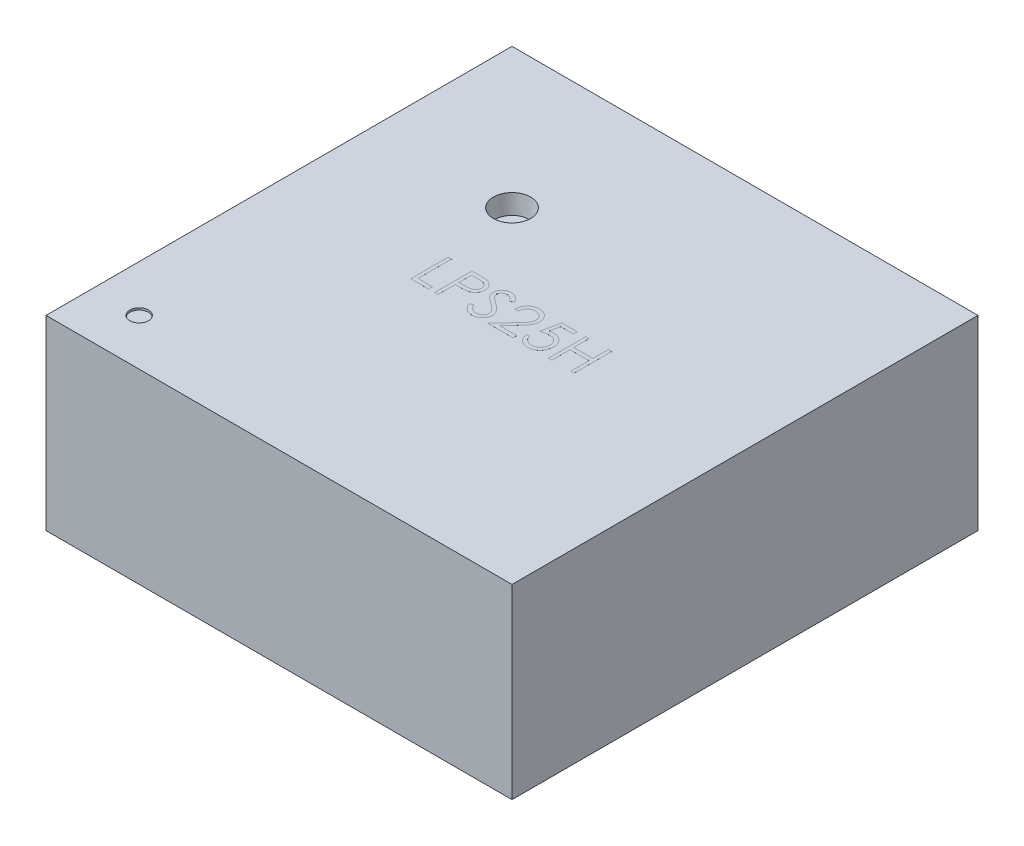
from build123d import *

# Parameters (mm, degrees)
SKETCH1_W           = 2.5
SKETCH1_H           = 2.5
BOSS_EXTRUDE1_DEPTH = 1
SKETCH2_R           = 0.1
CUT_EXTRUDE1_DEPTH  = 0.1
CUT_EXTRUDE1_TAPER  = 5
SKETCH3_R           = 0.05
CUT_EXTRUDE2_DEPTH  = 0.01
CUT_EXTRUDE2_TAPER  = 5
SKETCH4_R           = 0.075
CUT_EXTRUDE3_DEPTH  = 0.01
SKETCH5_W           = 0.45
SKETCH5_H           = 0.3
SKETCH5_W_2         = 0.3
SKETCH5_H_2         = 0.45
BOSS_EXTRUDE2_DEPTH = 0.025
BOSS_EXTRUDE3_DEPTH = 0.0001


with BuildPart() as part:
    # Sketch1 → Boss-Extrude1 (new body)
    with BuildSketch(Plane(origin=(0, 0, 0), x_dir=(1, 0, 0), z_dir=(0, 1, 0))):
        Rectangle(SKETCH1_W, SKETCH1_H)
    extrude(amount=BOSS_EXTRUDE1_DEPTH)

    # Sketch2 → Cut-Extrude1 (cut)
    with BuildSketch(Plane(origin=(0, 1, 0), x_dir=(1, 0, 0), z_dir=(0, 1, 0))):
        with Locations((-0.5, 0.5)):
            Circle(SKETCH2_R)
    extrude(amount=-CUT_EXTRUDE1_DEPTH, taper=CUT_EXTRUDE1_TAPER, mode=Mode.SUBTRACT)

    # Sketch3 → Cut-Extrude2 (cut)
    with BuildSketch(Plane(origin=(0, 1, 0), x_dir=(1, 0, 0), z_dir=(0, 1, 0))):
        with Locations((-1, -1)):
            Circle(SKETCH3_R)
    extrude(amount=-CUT_EXTRUDE2_DEPTH, taper=CUT_EXTRUDE2_TAPER, mode=Mode.SUBTRACT)

    # Sketch4 → Cut-Extrude3 (cut)
    with BuildSketch(Plane.XZ):
        with Locations((-0.75, 1.01)):
            Circle(SKETCH4_R)
    extrude(amount=-CUT_EXTRUDE3_DEPTH, mode=Mode.SUBTRACT)

    # Sketch5 → Boss-Extrude2 (add)
    with BuildSketch(Plane.XZ):
        with Locations((-0.925, 0.6)):
            Rectangle(SKETCH5_W, SKETCH5_H)
        with Locations((-0.925, 0)):
            Rectangle(SKETCH5_W, SKETCH5_H)
        with Locations((-0.925, -0.6)):
            Rectangle(SKETCH5_W, SKETCH5_H)
        with Locations((0.925, -0.6)):
            Rectangle(SKETCH5_W, SKETCH5_H)
        with Locations((0.925, 0.6)):
            Rectangle(SKETCH5_W, SKETCH5_H)
        with Locations((0.925, 0)):
            Rectangle(SKETCH5_W, SKETCH5_H)
        with Locations((-0.3, 0.925)):
            Rectangle(SKETCH5_W_2, SKETCH5_H_2)
        with Locations((0.3, 0.925)):
            Rectangle(SKETCH5_W_2, SKETCH5_H_2)
        with Locations((0.3, -0.925)):
            Rectangle(SKETCH5_W_2, SKETCH5_H_2)
        with Locations((-0.3, -0.925)):
            Rectangle(SKETCH5_W_2, SKETCH5_H_2)
    extrude(amount=BOSS_EXTRUDE2_DEPTH)

    # Sketch6 → Boss-Extrude3 (add)
    with BuildSketch(Plane(origin=(0, 1, 0), x_dir=(1, 0, 0), z_dir=(0, 1, 0))):
        Polygon((-0.441672664, 0.098543738), (-0.423723946, 0.098543738), (-0.423723946, -0.080943441), (-0.346800869, -0.080943441), (-0.346800869, -0.101456262), (-0.441672664, -0.101456262), align=None)
        with BuildLine():
            Line((-0.313467536, 0.098543738), (-0.274244779, 0.098543738))
            add(Edge.make_bspline(
                [(-0.274244779, 0.098543738), (-0.271547013, 0.098540773), (-0.266377974, 0.098535091), (-0.258965685, 0.09836282), (-0.2522337, 0.098132723), (-0.246196536, 0.097813758), (-0.240835616, 0.09743681), (-0.236175199, 0.096908122), (-0.232178653, 0.096356105), (-0.229783998, 0.095794882), (-0.228691895, 0.095538931)],
                knots=[0, 0, 0, 0, 8.093e-06, 1.5507e-05, 2.2242e-05, 2.83e-05, 3.3643e-05, 3.836e-05, 4.2371e-05, 4.5735e-05, 4.5735e-05, 4.5735e-05, 4.5735e-05], degree=3))
            add(Edge.make_bspline(
                [(-0.228691895, 0.095538931), (-0.227309407, 0.095160534), (-0.224577009, 0.094412656), (-0.220639806, 0.092914729), (-0.216893872, 0.091138605), (-0.213326354, 0.08911438), (-0.209981093, 0.086755205), (-0.206808176, 0.084156712), (-0.203835606, 0.081258908), (-0.201080097, 0.078094295), (-0.198549538, 0.074715997), (-0.196370699, 0.071073584), (-0.194546286, 0.067228367), (-0.192981527, 0.06318302), (-0.19185533, 0.058903573), (-0.191006936, 0.05441976), (-0.190468443, 0.049732064), (-0.190416868, 0.046528643), (-0.190390613, 0.044897905)],
                knots=[0, 0, 0, 0, 4.298e-06, 8.495e-06, 1.2617e-05, 1.6726e-05, 2.0783e-05, 2.4882e-05, 2.9018e-05, 3.3221e-05, 3.746e-05, 4.1665e-05, 4.593e-05, 5.0215e-05, 5.4657e-05, 5.9183e-05, 6.3899e-05, 6.879e-05, 6.879e-05, 6.879e-05, 6.879e-05], degree=3))
            add(Edge.make_bspline(
                [(-0.190390613, 0.044897905), (-0.190414694, 0.043253461), (-0.190461811, 0.040035994), (-0.191027313, 0.035328978), (-0.191789038, 0.030830784), (-0.192960299, 0.026551387), (-0.194494337, 0.0225162), (-0.196293883, 0.018663558), (-0.19846437, 0.015059005), (-0.200958361, 0.011689456), (-0.203732737, 0.008551747), (-0.206775762, 0.005668615), (-0.210075151, 0.003056939), (-0.213620416, 0.000710862), (-0.217446122, -0.001315211), (-0.221494245, -0.003129914), (-0.225799972, -0.004653975), (-0.228779544, -0.005455692), (-0.230294459, -0.005863313)],
                knots=[0, 0, 0, 0, 4.93e-06, 9.647e-06, 1.4205e-05, 1.8608e-05, 2.2931e-05, 2.7143e-05, 3.1348e-05, 3.5531e-05, 3.9703e-05, 4.3897e-05, 4.8089e-05, 5.2312e-05, 5.6632e-05, 6.1062e-05, 6.5611e-05, 7.0316e-05, 7.0316e-05, 7.0316e-05, 7.0316e-05], degree=3))
            add(Edge.make_bspline(
                [(-0.230294459, -0.005863313), (-0.231547449, -0.006129769), (-0.234293451, -0.006713723), (-0.238815892, -0.007365635), (-0.244081343, -0.007922069), (-0.250082616, -0.008339277), (-0.256814325, -0.008696441), (-0.264280111, -0.008980332), (-0.27249463, -0.009136324), (-0.278224415, -0.009144369), (-0.281215933, -0.009148569)],
                knots=[0, 0, 0, 0, 3.842e-06, 8.42e-06, 1.3699e-05, 1.9724e-05, 2.6465e-05, 3.3922e-05, 4.2137e-05, 5.1111e-05, 5.1111e-05, 5.1111e-05, 5.1111e-05], degree=3))
            Line((-0.281215933, -0.009148569), (-0.295518818, -0.009148569))
            Line((-0.295518818, -0.009148569), (-0.295518818, -0.101456262))
            Line((-0.295518818, -0.101456262), (-0.313467536, -0.101456262))
            Line((-0.313467536, -0.101456262), (-0.313467536, 0.098543738))
        make_face()
        with BuildLine():
            Line((-0.295518818, 0.078030918), (-0.295518818, 0.011364251))
            Line((-0.295518818, 0.011364251), (-0.260502792, 0.010923546))
            add(Edge.make_bspline(
                [(-0.260502792, 0.010923546), (-0.258793082, 0.010922662), (-0.255492522, 0.010920957), (-0.250724738, 0.011148684), (-0.24630135, 0.011411571), (-0.242235946, 0.011796481), (-0.238526693, 0.012340553), (-0.235167405, 0.012889795), (-0.232184132, 0.013684387), (-0.228692749, 0.014754277), (-0.224802272, 0.016578998), (-0.220569841, 0.019227563), (-0.21698295, 0.022603604), (-0.213879047, 0.02639948), (-0.211415854, 0.030622287), (-0.209612655, 0.035140512), (-0.20855316, 0.039907818), (-0.208411092, 0.043169997), (-0.208339331, 0.044817777)],
                knots=[0, 0, 0, 0, 5.128e-06, 9.9e-06, 1.4316e-05, 1.8422e-05, 2.2145e-05, 2.5563e-05, 2.8624e-05, 3.1399e-05, 3.6509e-05, 4.1465e-05, 4.6314e-05, 5.1213e-05, 5.6133e-05, 6.0917e-05, 6.5758e-05, 7.0699e-05, 7.0699e-05, 7.0699e-05, 7.0699e-05], degree=3))
            add(Edge.make_bspline(
                [(-0.208339331, 0.044817777), (-0.208411482, 0.046425692), (-0.20855491, 0.049622028), (-0.209620959, 0.054306529), (-0.211412348, 0.05877714), (-0.213895582, 0.062947031), (-0.216909361, 0.066729248), (-0.220412181, 0.070014798), (-0.224395796, 0.072656039), (-0.228101409, 0.074360798), (-0.231392905, 0.07540167), (-0.234251874, 0.076129947), (-0.237479913, 0.07671141), (-0.241078072, 0.077182239), (-0.245018462, 0.077585294), (-0.249334937, 0.077858778), (-0.254011146, 0.078018862), (-0.257257464, 0.078026802), (-0.258940292, 0.078030918)],
                knots=[0, 0, 0, 0, 4.821e-06, 9.584e-06, 1.433e-05, 1.9216e-05, 2.409e-05, 2.8796e-05, 3.3563e-05, 3.8367e-05, 4.0977e-05, 4.3912e-05, 4.7212e-05, 5.081e-05, 5.4797e-05, 5.9093e-05, 6.3783e-05, 6.8831e-05, 6.8831e-05, 6.8831e-05, 6.8831e-05], degree=3))
            Line((-0.258940292, 0.078030918), (-0.295518818, 0.078030918))
        make_face(mode=Mode.SUBTRACT)
        with BuildLine():
            Line((-0.169877792, -0.062874531), (-0.152970741, -0.052738313))
            add(Edge.make_bspline(
                [(-0.152970741, -0.052738313), (-0.15139827, -0.055370563), (-0.148385477, -0.060413854), (-0.143359685, -0.067228599), (-0.13815209, -0.073020722), (-0.132724128, -0.077756529), (-0.127108931, -0.081485036), (-0.121269843, -0.084125164), (-0.115226539, -0.085771791), (-0.111113749, -0.085971796), (-0.109060485, -0.086071646)],
                knots=[0, 0, 0, 0, 9.194e-06, 1.7616e-05, 2.5359e-05, 3.2516e-05, 3.9172e-05, 4.5502e-05, 5.1673e-05, 5.7824e-05, 5.7824e-05, 5.7824e-05, 5.7824e-05], degree=3))
            add(Edge.make_bspline(
                [(-0.109060485, -0.086071646), (-0.10730695, -0.086022808), (-0.103830563, -0.085925985), (-0.09871272, -0.084995654), (-0.093742332, -0.083566389), (-0.089021838, -0.081519479), (-0.084616374, -0.079042994), (-0.080753135, -0.076051784), (-0.077413357, -0.072702858), (-0.074681407, -0.068966706), (-0.072585405, -0.064948583), (-0.07097443, -0.060824243), (-0.070080426, -0.056528897), (-0.069945754, -0.05363687), (-0.069877792, -0.052177415)],
                knots=[0, 0, 0, 0, 5.256e-06, 1.042e-05, 1.5554e-05, 2.0741e-05, 2.582e-05, 3.0676e-05, 3.5351e-05, 3.9967e-05, 4.4501e-05, 4.8913e-05, 5.3211e-05, 5.759e-05, 5.759e-05, 5.759e-05, 5.759e-05], degree=3))
            add(Edge.make_bspline(
                [(-0.069877792, -0.052177415), (-0.069962039, -0.050512224), (-0.070133299, -0.047127133), (-0.071580812, -0.042132867), (-0.073857912, -0.037190435), (-0.075958635, -0.03413322), (-0.077049267, -0.032546005)],
                knots=[0, 0, 0, 0, 4.987e-06, 1.0139e-05, 1.5481e-05, 2.1248e-05, 2.1248e-05, 2.1248e-05, 2.1248e-05], degree=3))
            add(Edge.make_bspline(
                [(-0.077049267, -0.032546005), (-0.07794473, -0.031400472), (-0.079824644, -0.02899557), (-0.083056502, -0.025415842), (-0.086848852, -0.021723361), (-0.091071912, -0.017777129), (-0.095879517, -0.013760683), (-0.101121089, -0.009482496), (-0.106930453, -0.005105263), (-0.111004709, -0.002169688), (-0.113106959, -0.00065498)],
                knots=[0, 0, 0, 0, 4.361e-06, 9.156e-06, 1.4453e-05, 2.0237e-05, 2.649e-05, 3.3242e-05, 4.0533e-05, 4.8307e-05, 4.8307e-05, 4.8307e-05, 4.8307e-05], degree=3))
            add(Edge.make_bspline(
                [(-0.113106959, -0.00065498), (-0.115211187, 0.000843797), (-0.119234312, 0.003709343), (-0.124860516, 0.00796216), (-0.129891629, 0.011850381), (-0.134305287, 0.01541061), (-0.138099549, 0.01864333), (-0.141304316, 0.021517498), (-0.143837948, 0.024110844), (-0.145246838, 0.025793207), (-0.145879395, 0.026548546)],
                knots=[0, 0, 0, 0, 7.75e-06, 1.4817e-05, 2.1156e-05, 2.6825e-05, 3.1827e-05, 3.6109e-05, 3.9736e-05, 4.2691e-05, 4.2691e-05, 4.2691e-05, 4.2691e-05], degree=3))
            add(Edge.make_bspline(
                [(-0.145879395, 0.026548546), (-0.14676354, 0.027725748), (-0.148502331, 0.030040874), (-0.150797531, 0.033659437), (-0.152748341, 0.037363624), (-0.154277617, 0.041163388), (-0.155565401, 0.045005384), (-0.156431568, 0.048939741), (-0.156973934, 0.052948804), (-0.157029476, 0.055646719), (-0.157057279, 0.056997264)],
                knots=[0, 0, 0, 0, 4.415e-06, 8.684e-06, 1.2841e-05, 1.6955e-05, 2.0959e-05, 2.4983e-05, 2.9023e-05, 3.3073e-05, 3.3073e-05, 3.3073e-05, 3.3073e-05], degree=3))
            add(Edge.make_bspline(
                [(-0.157057279, 0.056997264), (-0.156982696, 0.059113251), (-0.156835124, 0.063299998), (-0.155587094, 0.069416045), (-0.153617214, 0.075255269), (-0.150857506, 0.080759859), (-0.147299943, 0.085786487), (-0.143183031, 0.090392972), (-0.138279517, 0.094265462), (-0.132899367, 0.097649009), (-0.127010432, 0.100297347), (-0.120839523, 0.102295117), (-0.114376833, 0.103427075), (-0.109999511, 0.103589519), (-0.107778433, 0.103671944)],
                knots=[0, 0, 0, 0, 6.343e-06, 1.255e-05, 1.8644e-05, 2.479e-05, 3.0947e-05, 3.7073e-05, 4.3255e-05, 4.9625e-05, 5.6097e-05, 6.2572e-05, 6.904e-05, 7.5703e-05, 7.5703e-05, 7.5703e-05, 7.5703e-05], degree=3))
            add(Edge.make_bspline(
                [(-0.107778433, 0.103671944), (-0.105421628, 0.103590655), (-0.100734693, 0.103428998), (-0.093840452, 0.102023424), (-0.087202697, 0.099697672), (-0.081863082, 0.09705832), (-0.077684067, 0.094422239), (-0.074497054, 0.092021106), (-0.071267485, 0.089256814), (-0.067969311, 0.086122), (-0.064658416, 0.0825879), (-0.061285647, 0.078678718), (-0.057843117, 0.074418343), (-0.055628497, 0.071376943), (-0.054493177, 0.069817777)],
                knots=[0, 0, 0, 0, 7.065e-06, 1.405e-05, 2.1006e-05, 2.8119e-05, 3.1865e-05, 3.5815e-05, 4.0078e-05, 4.4613e-05, 4.9459e-05, 5.46e-05, 6.01e-05, 6.5885e-05, 6.5885e-05, 6.5885e-05, 6.5885e-05], degree=3))
            Line((-0.054493177, 0.069817777), (-0.070719138, 0.057518097))
            add(Edge.make_bspline(
                [(-0.070719138, 0.057518097), (-0.071698906, 0.058780308), (-0.073585709, 0.061211031), (-0.076450251, 0.064615106), (-0.079150174, 0.06772462), (-0.081810197, 0.070425484), (-0.084289833, 0.072865606), (-0.086696521, 0.074954735), (-0.088995627, 0.07671334), (-0.091893736, 0.078590115), (-0.095534749, 0.080450487), (-0.100105294, 0.08202472), (-0.104881652, 0.082970723), (-0.108134774, 0.083095803), (-0.109781638, 0.083159123)],
                knots=[0, 0, 0, 0, 4.793e-06, 9.23e-06, 1.3346e-05, 1.7142e-05, 2.0599e-05, 2.378e-05, 2.6697e-05, 2.9275e-05, 3.4131e-05, 3.892e-05, 4.3737e-05, 4.8675e-05, 4.8675e-05, 4.8675e-05, 4.8675e-05], degree=3))
            add(Edge.make_bspline(
                [(-0.109781638, 0.083159123), (-0.111847725, 0.083089883), (-0.11583198, 0.08295636), (-0.121488565, 0.081498075), (-0.126579646, 0.079201969), (-0.130954078, 0.07598397), (-0.134596191, 0.072171342), (-0.137230789, 0.067783979), (-0.138816513, 0.06293927), (-0.139010014, 0.059559747), (-0.139108562, 0.05783861)],
                knots=[0, 0, 0, 0, 6.186e-06, 1.1928e-05, 1.7396e-05, 2.2845e-05, 2.8117e-05, 3.3113e-05, 3.8079e-05, 4.3234e-05, 4.3234e-05, 4.3234e-05, 4.3234e-05], degree=3))
            add(Edge.make_bspline(
                [(-0.139108562, 0.05783861), (-0.139086097, 0.056767097), (-0.139041132, 0.054622319), (-0.138414, 0.051453666), (-0.137608324, 0.048293018), (-0.136331603, 0.045154585), (-0.134569014, 0.041983479), (-0.132254432, 0.038725094), (-0.129339386, 0.03535071), (-0.127106414, 0.033156003), (-0.125927472, 0.031997264)],
                knots=[0, 0, 0, 0, 3.209e-06, 6.424e-06, 9.66e-06, 1.2985e-05, 1.6554e-05, 2.0522e-05, 2.4954e-05, 2.9912e-05, 2.9912e-05, 2.9912e-05, 2.9912e-05], degree=3))
            add(Edge.make_bspline(
                [(-0.125927472, 0.031997264), (-0.125489679, 0.031606577), (-0.124449584, 0.030678394), (-0.122548102, 0.029158835), (-0.120037085, 0.027284391), (-0.116982102, 0.024965115), (-0.113326825, 0.022274746), (-0.10907085, 0.019247682), (-0.104261619, 0.015785656), (-0.100848939, 0.013365225), (-0.099044459, 0.012085405)],
                knots=[0, 0, 0, 0, 1.76e-06, 4.182e-06, 7.299e-06, 1.1161e-05, 1.5688e-05, 2.0914e-05, 2.6829e-05, 3.3465e-05, 3.3465e-05, 3.3465e-05, 3.3465e-05], degree=3))
            add(Edge.make_bspline(
                [(-0.099044459, 0.012085405), (-0.096873835, 0.010505899), (-0.092670724, 0.007447404), (-0.08669029, 0.002852222), (-0.081267787, -0.001641936), (-0.076384175, -0.006006371), (-0.071991209, -0.010207976), (-0.068137625, -0.014297301), (-0.064784158, -0.018245048), (-0.061173917, -0.023306338), (-0.057484898, -0.0295224), (-0.054316812, -0.037138299), (-0.052319192, -0.044783803), (-0.052057963, -0.049922479), (-0.051929074, -0.052457864)],
                knots=[0, 0, 0, 0, 8.053e-06, 1.5594e-05, 2.2622e-05, 2.9176e-05, 3.524e-05, 4.0852e-05, 4.6028e-05, 5.0764e-05, 5.9491e-05, 6.7645e-05, 7.5448e-05, 8.3047e-05, 8.3047e-05, 8.3047e-05, 8.3047e-05], degree=3))
            add(Edge.make_bspline(
                [(-0.051929074, -0.052457864), (-0.051966625, -0.054250914), (-0.052040997, -0.057802193), (-0.052895907, -0.063016768), (-0.054148459, -0.06808139), (-0.056036301, -0.072933453), (-0.058340481, -0.077661725), (-0.061264267, -0.082142177), (-0.064653278, -0.086473971), (-0.068540921, -0.090541599), (-0.072794973, -0.094275667), (-0.077291184, -0.097597328), (-0.082036914, -0.100366947), (-0.087006418, -0.102626995), (-0.092200837, -0.104394624), (-0.097618425, -0.10567536), (-0.103268111, -0.1064614), (-0.107108138, -0.106542987), (-0.109060485, -0.106584467)],
                knots=[0, 0, 0, 0, 5.374e-06, 1.0644e-05, 1.5813e-05, 2.0999e-05, 2.6231e-05, 3.1566e-05, 3.7016e-05, 4.2712e-05, 4.8418e-05, 5.3979e-05, 5.9456e-05, 6.487e-05, 7.0331e-05, 7.5889e-05, 8.155e-05, 8.7404e-05, 8.7404e-05, 8.7404e-05, 8.7404e-05], degree=3))
            add(Edge.make_bspline(
                [(-0.109060485, -0.106584467), (-0.110571076, -0.106555256), (-0.113573233, -0.106497203), (-0.118013775, -0.105983987), (-0.122364609, -0.105257867), (-0.126571139, -0.104105063), (-0.130687563, -0.102706379), (-0.134695976, -0.100984188), (-0.138598322, -0.098920348), (-0.14241647, -0.096560633), (-0.146140708, -0.093814476), (-0.149736106, -0.09061599), (-0.153320631, -0.08705339), (-0.156788483, -0.083029929), (-0.160209805, -0.07861061), (-0.163517143, -0.073754085), (-0.166778955, -0.068486808), (-0.168825553, -0.064780232), (-0.169877792, -0.062874531)],
                knots=[0, 0, 0, 0, 4.53e-06, 9.003e-06, 1.3396e-05, 1.775e-05, 2.2071e-05, 2.6432e-05, 3.0822e-05, 3.5303e-05, 3.9886e-05, 4.4684e-05, 4.9727e-05, 5.5037e-05, 6.0607e-05, 6.6485e-05, 7.2656e-05, 7.9186e-05, 7.9186e-05, 7.9186e-05, 7.9186e-05], degree=3))
        make_face()
        with BuildLine():
            Line((-0.003211126, 0.037005277), (-0.021159844, 0.037005277))
            add(Edge.make_bspline(
                [(-0.021159844, 0.037005277), (-0.021042863, 0.03938647), (-0.020813117, 0.044063071), (-0.019737215, 0.05088158), (-0.018197737, 0.057398997), (-0.016021082, 0.063562992), (-0.013317866, 0.069428067), (-0.01007615, 0.074970925), (-0.006236502, 0.080170422), (-0.001881831, 0.084978356), (0.002847805, 0.089389074), (0.007951002, 0.093197945), (0.013313575, 0.096416098), (0.018919255, 0.099106454), (0.024831287, 0.101125874), (0.030996022, 0.102624253), (0.037440544, 0.103525759), (0.041831402, 0.103622661), (0.044064515, 0.103671944)],
                knots=[0, 0, 0, 0, 7.148e-06, 1.4038e-05, 2.0675e-05, 2.7213e-05, 3.3612e-05, 4.0023e-05, 4.6442e-05, 5.2966e-05, 5.9459e-05, 6.5813e-05, 7.2031e-05, 7.8196e-05, 8.443e-05, 9.0736e-05, 9.7207e-05, 0.000103903, 0.000103903, 0.000103903, 0.000103903], degree=3))
            add(Edge.make_bspline(
                [(0.044064515, 0.103671944), (0.046257548, 0.103620603), (0.050566779, 0.103519721), (0.056856037, 0.102653377), (0.062843311, 0.101296486), (0.068516898, 0.099392748), (0.07383153, 0.096833637), (0.078827133, 0.093759492), (0.083563179, 0.090204073), (0.087826424, 0.086018141), (0.091741171, 0.081549434), (0.095118443, 0.076778696), (0.098010624, 0.071851309), (0.100421348, 0.066729697), (0.102195985, 0.061365638), (0.103543311, 0.055837227), (0.104304877, 0.050087237), (0.104421759, 0.046195434), (0.104481182, 0.044216815)],
                knots=[0, 0, 0, 0, 6.576e-06, 1.2923e-05, 1.9007e-05, 2.4974e-05, 3.0834e-05, 3.6661e-05, 4.255e-05, 4.8557e-05, 5.455e-05, 6.0353e-05, 6.6063e-05, 7.1673e-05, 7.7299e-05, 8.2983e-05, 8.8723e-05, 9.4659e-05, 9.4659e-05, 9.4659e-05, 9.4659e-05], degree=3))
            add(Edge.make_bspline(
                [(0.104481182, 0.044216815), (0.104384424, 0.041431225), (0.104192606, 0.035908927), (0.102551785, 0.027793792), (0.099989127, 0.019931311), (0.096903564, 0.013603465), (0.093790853, 0.008504408), (0.090985852, 0.004306196), (0.087702149, -0.000214116), (0.083891949, -0.005041392), (0.079634071, -0.010213444), (0.074889947, -0.015727147), (0.069625748, -0.021525534), (0.065930976, -0.025485854), (0.064016438, -0.027537992)],
                knots=[0, 0, 0, 0, 8.35e-06, 1.6553e-05, 2.4737e-05, 3.3105e-05, 3.7599e-05, 4.2655e-05, 4.8248e-05, 5.4355e-05, 6.1101e-05, 6.8345e-05, 7.6174e-05, 8.4594e-05, 8.4594e-05, 8.4594e-05, 8.4594e-05], degree=3))
            Line((0.064016438, -0.027537992), (0.013976374, -0.080943441))
            Line((0.013976374, -0.080943441), (0.107045285, -0.080943441))
            Line((0.107045285, -0.080943441), (0.107045285, -0.101456262))
            Line((0.107045285, -0.101456262), (-0.028852151, -0.101456262))
            Line((-0.028852151, -0.101456262), (0.048711951, -0.018683826))
            add(Edge.make_bspline(
                [(0.048711951, -0.018683826), (0.050600402, -0.016712494), (0.054227729, -0.012925969), (0.059358162, -0.0073978), (0.063966104, -0.002269255), (0.068081384, 0.002449977), (0.071614727, 0.006828923), (0.074750283, 0.010725764), (0.077262603, 0.014311732), (0.079989197, 0.018468339), (0.082629996, 0.023543328), (0.084899273, 0.029745253), (0.086282979, 0.036129668), (0.086448969, 0.04044407), (0.086532464, 0.042614251)],
                knots=[0, 0, 0, 0, 8.19e-06, 1.5731e-05, 2.2625e-05, 2.8874e-05, 3.4511e-05, 3.9505e-05, 4.3873e-05, 4.7641e-05, 5.4414e-05, 6.0979e-05, 6.7407e-05, 7.3912e-05, 7.3912e-05, 7.3912e-05, 7.3912e-05], degree=3))
            add(Edge.make_bspline(
                [(0.086532464, 0.042614251), (0.086496136, 0.043978903), (0.08642454, 0.046668368), (0.085792672, 0.050611555), (0.084837786, 0.054415258), (0.083469485, 0.058091179), (0.081663386, 0.061602359), (0.079464907, 0.064953073), (0.076928332, 0.068192442), (0.073993974, 0.071229773), (0.070770458, 0.074011556), (0.067365073, 0.07647579), (0.063762209, 0.078535168), (0.05997706, 0.080223368), (0.056020176, 0.081547675), (0.051883905, 0.082465308), (0.047579675, 0.08304145), (0.044640618, 0.083119403), (0.043143041, 0.083159123)],
                knots=[0, 0, 0, 0, 4.091e-06, 8.063e-06, 1.195e-05, 1.5842e-05, 1.9802e-05, 2.3769e-05, 2.7849e-05, 3.2128e-05, 3.6417e-05, 4.0608e-05, 4.4718e-05, 4.8843e-05, 5.3024e-05, 5.7213e-05, 6.1536e-05, 6.6028e-05, 6.6028e-05, 6.6028e-05, 6.6028e-05], degree=3))
            add(Edge.make_bspline(
                [(0.043143041, 0.083159123), (0.041578993, 0.083118264), (0.038507462, 0.083038024), (0.033997803, 0.082476729), (0.029695759, 0.081508395), (0.025590507, 0.080184014), (0.021675102, 0.078500668), (0.017968585, 0.076403997), (0.014479278, 0.073902083), (0.011200619, 0.07106548), (0.00817982, 0.067907331), (0.005525713, 0.064386762), (0.003206627, 0.060568052), (0.001183242, 0.056461506), (-0.000459941, 0.052029862), (-0.001715549, 0.04728885), (-0.002709083, 0.042259057), (-0.003040999, 0.038785624), (-0.003211126, 0.037005277)],
                knots=[0, 0, 0, 0, 4.692e-06, 9.214e-06, 1.3607e-05, 1.7902e-05, 2.2137e-05, 2.6371e-05, 3.0651e-05, 3.4997e-05, 3.9361e-05, 4.3736e-05, 4.8196e-05, 5.2747e-05, 5.745e-05, 6.2348e-05, 6.7448e-05, 7.281e-05, 7.281e-05, 7.281e-05, 7.281e-05], degree=3))
        make_face()
        with BuildLine():
            Line((0.250635028, 0.098543738), (0.250635028, 0.078030918))
            Line((0.250635028, 0.078030918), (0.182606182, 0.078030918))
            Line((0.182606182, 0.078030918), (0.171828938, 0.025426751))
            add(Edge.make_bspline(
                [(0.171828938, 0.025426751), (0.173946417, 0.026011338), (0.178048697, 0.027143883), (0.184103546, 0.028401356), (0.189851672, 0.029159381), (0.193581693, 0.029262884), (0.195386631, 0.029312969)],
                knots=[0, 0, 0, 0, 6.589e-06, 1.2765e-05, 1.8539e-05, 2.3953e-05, 2.3953e-05, 2.3953e-05, 2.3953e-05], degree=3))
            add(Edge.make_bspline(
                [(0.195386631, 0.029312969), (0.197619987, 0.02926463), (0.202011324, 0.029169583), (0.208436407, 0.028256906), (0.214569715, 0.026820339), (0.220398422, 0.024813452), (0.225933311, 0.022247182), (0.231123457, 0.019041471), (0.236046766, 0.015296709), (0.240614915, 0.01099128), (0.244759161, 0.006252902), (0.248402932, 0.001158167), (0.251497937, -0.004243414), (0.253987123, -0.010003449), (0.255974799, -0.016058258), (0.25729777, -0.022471548), (0.258178725, -0.029182869), (0.258277147, -0.033771702), (0.258327336, -0.03611171)],
                knots=[0, 0, 0, 0, 6.697e-06, 1.3167e-05, 1.9425e-05, 2.557e-05, 3.1629e-05, 3.7689e-05, 4.3835e-05, 5.0156e-05, 5.6487e-05, 6.2691e-05, 6.8918e-05, 7.5125e-05, 8.1485e-05, 8.8e-05, 9.4743e-05, 0.00010176, 0.00010176, 0.00010176, 0.00010176], degree=3))
            add(Edge.make_bspline(
                [(0.258327336, -0.03611171), (0.258289332, -0.037741551), (0.258213837, -0.040979208), (0.257829917, -0.045787448), (0.257090734, -0.050493896), (0.256098292, -0.055099175), (0.254810154, -0.059594568), (0.253250779, -0.063992941), (0.251342435, -0.068266918), (0.249249214, -0.072456941), (0.246892272, -0.076468284), (0.244276357, -0.080219655), (0.241512615, -0.083767328), (0.238538821, -0.087073256), (0.235327336, -0.090115714), (0.231917052, -0.092912758), (0.228335183, -0.095511692), (0.224526312, -0.097807017), (0.220575313, -0.099919186), (0.216425129, -0.10165196), (0.212170232, -0.103201133), (0.207749382, -0.104435963), (0.203172592, -0.105403537), (0.198432319, -0.106060714), (0.193553424, -0.106539368), (0.19024628, -0.106569331), (0.188575733, -0.106584467)],
                knots=[0, 0, 0, 0, 4.89e-06, 9.715e-06, 1.4457e-05, 1.9172e-05, 2.3839e-05, 2.8477e-05, 3.3159e-05, 3.7872e-05, 4.2523e-05, 4.7102e-05, 5.1582e-05, 5.6008e-05, 6.0428e-05, 6.484e-05, 6.9232e-05, 7.3691e-05, 7.8172e-05, 8.2659e-05, 8.717e-05, 9.1749e-05, 9.6417e-05, 0.000101193, 0.000106101, 0.00011111, 0.00011111, 0.00011111, 0.00011111], degree=3))
            add(Edge.make_bspline(
                [(0.188575733, -0.106584467), (0.186582923, -0.10654499), (0.182662304, -0.106467325), (0.176918272, -0.10565484), (0.171391723, -0.104491188), (0.166127146, -0.102740544), (0.161077359, -0.100546984), (0.156310347, -0.097774631), (0.151704302, -0.094632968), (0.147446472, -0.09092552), (0.143494694, -0.086873195), (0.139957179, -0.082475615), (0.136806689, -0.077805362), (0.134093675, -0.072839753), (0.131779502, -0.067591837), (0.129961503, -0.062041951), (0.128494168, -0.056219094), (0.127873401, -0.052210322), (0.127558105, -0.05017421)],
                knots=[0, 0, 0, 0, 5.974e-06, 1.1754e-05, 1.7373e-05, 2.2897e-05, 2.8368e-05, 3.3859e-05, 3.9416e-05, 4.507e-05, 5.0764e-05, 5.6377e-05, 6.1977e-05, 6.7643e-05, 7.333e-05, 7.9158e-05, 8.5144e-05, 9.1322e-05, 9.1322e-05, 9.1322e-05, 9.1322e-05], degree=3))
            Line((0.127558105, -0.05017421), (0.145506823, -0.05017421))
            add(Edge.make_bspline(
                [(0.145506823, -0.05017421), (0.145948455, -0.052081436), (0.146797296, -0.05574723), (0.148660482, -0.060897593), (0.150938532, -0.065487262), (0.153647351, -0.069576953), (0.156878782, -0.073143181), (0.160566178, -0.076321299), (0.164700333, -0.079188449), (0.169294232, -0.081578322), (0.174140694, -0.083616536), (0.179213106, -0.084973776), (0.184373354, -0.085928113), (0.187863547, -0.086023642), (0.1896174, -0.086071646)],
                knots=[0, 0, 0, 0, 5.869e-06, 1.1281e-05, 1.6387e-05, 2.121e-05, 2.5948e-05, 3.0776e-05, 3.5788e-05, 4.1003e-05, 4.6285e-05, 5.1525e-05, 5.6728e-05, 6.1984e-05, 6.1984e-05, 6.1984e-05, 6.1984e-05], degree=3))
            add(Edge.make_bspline(
                [(0.1896174, -0.086071646), (0.191329311, -0.086024745), (0.194700078, -0.085932395), (0.199660729, -0.085221594), (0.204450036, -0.084126876), (0.209020742, -0.082488599), (0.21345283, -0.080497472), (0.217634188, -0.077942325), (0.221685781, -0.075001752), (0.225481675, -0.071632802), (0.228958215, -0.067920248), (0.232029993, -0.063950111), (0.234588674, -0.059714863), (0.236744908, -0.055287825), (0.23838224, -0.050620479), (0.239550296, -0.045734698), (0.240236185, -0.040618413), (0.240330538, -0.037128738), (0.240378618, -0.035350492)],
                knots=[0, 0, 0, 0, 5.134e-06, 1.0109e-05, 1.5006e-05, 1.9847e-05, 2.4651e-05, 2.9557e-05, 3.4517e-05, 3.9655e-05, 4.4757e-05, 4.9757e-05, 5.4684e-05, 5.9576e-05, 6.4505e-05, 6.949e-05, 7.4623e-05, 7.9957e-05, 7.9957e-05, 7.9957e-05, 7.9957e-05], degree=3))
            add(Edge.make_bspline(
                [(0.240378618, -0.035350492), (0.240340991, -0.033746164), (0.24026734, -0.030605919), (0.239665593, -0.026011678), (0.238618909, -0.021664647), (0.237166116, -0.017543834), (0.235321573, -0.013645351), (0.233067498, -0.009965177), (0.230361589, -0.006551815), (0.227270624, -0.003403669), (0.223884451, -0.000498247), (0.220144808, 0.001978558), (0.216129955, 0.00406221), (0.211888264, 0.005860381), (0.207318841, 0.007151853), (0.202512176, 0.008121446), (0.197416364, 0.008682324), (0.193932325, 0.008760146), (0.192141438, 0.008800149)],
                knots=[0, 0, 0, 0, 4.812e-06, 9.419e-06, 1.3869e-05, 1.8203e-05, 2.2504e-05, 2.6785e-05, 3.1121e-05, 3.5541e-05, 4.0004e-05, 4.4482e-05, 4.8962e-05, 5.356e-05, 5.8276e-05, 6.3179e-05, 6.8258e-05, 7.3631e-05, 7.3631e-05, 7.3631e-05, 7.3631e-05], degree=3))
            add(Edge.make_bspline(
                [(0.192141438, 0.008800149), (0.190591214, 0.008766972), (0.187390394, 0.008698471), (0.182480518, 0.008194099), (0.177320991, 0.007380425), (0.171931591, 0.006261211), (0.166296133, 0.004796578), (0.160426511, 0.003041464), (0.154310381, 0.000943064), (0.150189368, -0.000641634), (0.148070926, -0.001456262)],
                knots=[0, 0, 0, 0, 4.65e-06, 9.601e-06, 1.4792e-05, 2.0316e-05, 2.6107e-05, 3.2255e-05, 3.8691e-05, 4.55e-05, 4.55e-05, 4.55e-05, 4.55e-05], degree=3))
            Line((0.148070926, -0.001456262), (0.168583746, 0.098543738))
            Line((0.168583746, 0.098543738), (0.250635028, 0.098543738))
        make_face()
        Polygon((0.296788874, 0.098543738), (0.314737592, 0.098543738), (0.314737592, 0.016492456), (0.417301695, 0.016492456), (0.417301695, 0.098543738), (0.435250413, 0.098543738), (0.435250413, -0.101456262), (0.417301695, -0.101456262), (0.417301695, -0.004020364), (0.314737592, -0.004020364), (0.314737592, -0.101456262), (0.296788874, -0.101456262), align=None)
    extrude(amount=BOSS_EXTRUDE3_DEPTH)


solid = part.part
